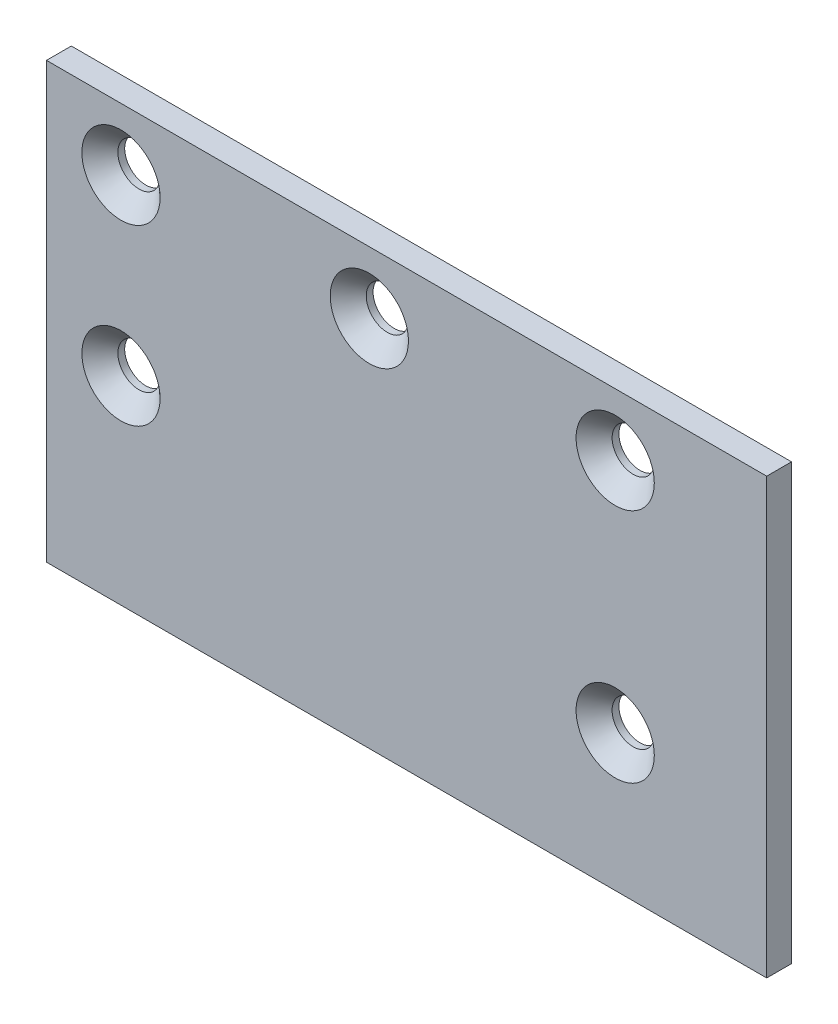
from build123d import *

# Parameters (mm, degrees)
SKETCH1_W                                    = 58
SKETCH1_H                                    = 35
BOSS_EXTRUDE1_DEPTH                          = 2
CSK_FOR_M3_FLAT_COUNTERSUNK_HEAD_SCR_2_COUNT = 2
CSK_FOR_M3_FLAT_COUNTERSUNK_HEAD_SCR_2_PITCH = 20
CSK_FOR_M3_FLAT_COUNTERSUNK_HEAD_SCR_3_COUNT = 2
CSK_FOR_M3_FLAT_COUNTERSUNK_HEAD_SCR_3_PITCH = 39.8
CSK_FOR_M3_FLAT_COUNTERSUNK_HEAD_SCR_4_COUNT = 2
CSK_FOR_M3_FLAT_COUNTERSUNK_HEAD_SCR_4_PITCH = 44.102607633
CSK_FOR_M3_FLAT_COUNTERSUNK_HEAD_SCR_5_COUNT = 2
CSK_FOR_M3_FLAT_COUNTERSUNK_HEAD_SCR_5_PITCH = 14


with BuildPart() as part:
    # Sketch1 → Boss-Extrude1 (new body)
    with BuildSketch(Plane.XY):
        Rectangle(SKETCH1_W, SKETCH1_H)
    extrude(amount=BOSS_EXTRUDE1_DEPTH)

    # Sketch3 → CSK for M3 Flat Countersunk Head Screw1 (revolve, cut)
    with BuildSketch(Plane(origin=(-23, 12.5, 2), x_dir=(0, -1, 0), z_dir=(1, 0, 0))):
        Polygon((0, 0), (0, 2), (1.7, 2), (1.7, 1.45), (3.15, 0), align=None)
    csk_for_m3_flat_countersunk_head_screw1 = revolve(axis=Axis((-23, 12.5, 8.35), (0, 0, -1)), mode=Mode.SUBTRACT)

    # CSK for M3 Flat Countersunk Head Scr 2: CSK for M3 Flat Countersunk Head Screw1 ×2
    with Locations(*[(i * CSK_FOR_M3_FLAT_COUNTERSUNK_HEAD_SCR_2_PITCH, 0, 0) for i in range(1, CSK_FOR_M3_FLAT_COUNTERSUNK_HEAD_SCR_2_COUNT)]):
        add(csk_for_m3_flat_countersunk_head_screw1, mode=Mode.SUBTRACT)

    # CSK for M3 Flat Countersunk Head Scr 3: CSK for M3 Flat Countersunk Head Screw1 ×2
    with Locations(*[(i * CSK_FOR_M3_FLAT_COUNTERSUNK_HEAD_SCR_3_PITCH, 0, 0) for i in range(1, CSK_FOR_M3_FLAT_COUNTERSUNK_HEAD_SCR_3_COUNT)]):
        add(csk_for_m3_flat_countersunk_head_screw1, mode=Mode.SUBTRACT)

    # CSK for M3 Flat Countersunk Head Scr 4: CSK for M3 Flat Countersunk Head Screw1 ×2
    with Locations(*[Vector(0.90244097, -0.430813528, 0) * (i * CSK_FOR_M3_FLAT_COUNTERSUNK_HEAD_SCR_4_PITCH) for i in range(1, CSK_FOR_M3_FLAT_COUNTERSUNK_HEAD_SCR_4_COUNT)]):
        add(csk_for_m3_flat_countersunk_head_screw1, mode=Mode.SUBTRACT)

    # CSK for M3 Flat Countersunk Head Scr 5: CSK for M3 Flat Countersunk Head Screw1 ×2
    with Locations(*[(0, -i * CSK_FOR_M3_FLAT_COUNTERSUNK_HEAD_SCR_5_PITCH, 0) for i in range(1, CSK_FOR_M3_FLAT_COUNTERSUNK_HEAD_SCR_5_COUNT)]):
        add(csk_for_m3_flat_countersunk_head_screw1, mode=Mode.SUBTRACT)


solid = part.part
